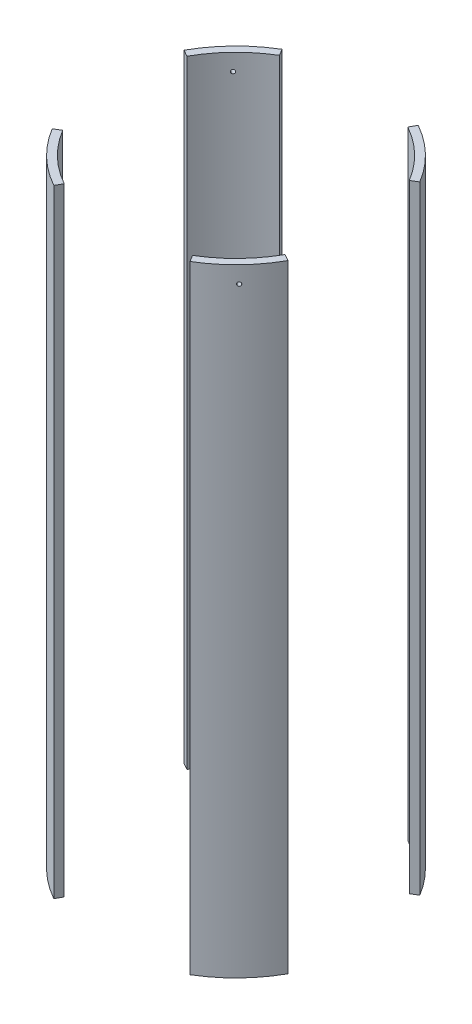
from build123d import *

# Parameters (mm, degrees)
SKETCH2_R               = 88.9
SKETCH2_R_2             = 83.82
BOSS_EXTRUDE1_DEPTH     = 204.94625
CUT_EXTRUDE1_DEPTH      = 205.94625
CUT_EXTRUDE1_DEPTH_BACK = 205.94625
SKETCH5_R               = 1.27
TOP_BOLT_HOLES_DEPTH    = 29.911624556
SKETCH6_R               = 1.27
BOTTOM_BOLT_HOLES_DEPTH = 31.75
BOLT_PATTERN_COUNT      = 4


with BuildPart() as part:
    # Sketch2 → Boss-Extrude1 (new body, symmetric)
    with BuildSketch(Plane(origin=(0, 0, 0), x_dir=(1, 0, 0), z_dir=(0, 1, 0))):
        Circle(SKETCH2_R)
        Circle(SKETCH2_R_2, mode=Mode.SUBTRACT)
    extrude(amount=BOSS_EXTRUDE1_DEPTH, both=True)

    # Sketch3 → Cut-Extrude1 (cut, two sides)
    with BuildSketch(Plane(origin=(0, 0, 0), x_dir=(1, 0, 0), z_dir=(0, 1, 0))) as cut_extrude1_sk:
        Polygon((169.661755759, -94.300371224), (0, 0), (169.661755759, 101.677593364), align=None)
        Polygon((0, 0), (53.900027233, 96.974944394), (-58.116685864, 96.974944394), align=None)
        Polygon((-123.741299607, 68.777140945), (-123.741299607, -74.157652604), (0, 0), align=None)
        Polygon((-65.840936026, -118.45858783), (0, 0), (70.991745134, -118.45858783), align=None)
    extrude(amount=CUT_EXTRUDE1_DEPTH, mode=Mode.SUBTRACT)
    extrude(cut_extrude1_sk.sketch, amount=-CUT_EXTRUDE1_DEPTH_BACK, mode=Mode.SUBTRACT)

    # Sketch5 → Top bolt holes (cut, through all)
    with BuildSketch(Plane(origin=(-56.309218645, 0, 58.175814955), x_dir=(-0.718540152, 0, -0.695485478), z_dir=(0.695485478, 0, -0.718540152))):
        with Locations((-0.02278764, 193.83375)):
            Circle(SKETCH5_R)
    top_bolt_holes = extrude(amount=-TOP_BOLT_HOLES_DEPTH, mode=Mode.SUBTRACT)

    # Sketch6 → Bottom bolt holes (cut)
    with BuildSketch(Plane(origin=(0, -204.94625, 0), x_dir=(-1, 0, 0), z_dir=(0, -1, 0))):
        with Locations((60.062125915, -62.053127484)):
            Circle(SKETCH6_R)
    bottom_bolt_holes = extrude(amount=-BOTTOM_BOLT_HOLES_DEPTH, mode=Mode.SUBTRACT)

    # Bolt pattern: Top bolt holes, Bottom bolt holes ×4 about axis
    bolt_pattern_axis = Axis((0, 0, 0), (0, 1, 0))
    for i in range(1, BOLT_PATTERN_COUNT):
        add(top_bolt_holes.rotate(bolt_pattern_axis, i * 360 / BOLT_PATTERN_COUNT), mode=Mode.SUBTRACT)
        add(bottom_bolt_holes.rotate(bolt_pattern_axis, i * 360 / BOLT_PATTERN_COUNT), mode=Mode.SUBTRACT)


solid = part.part
